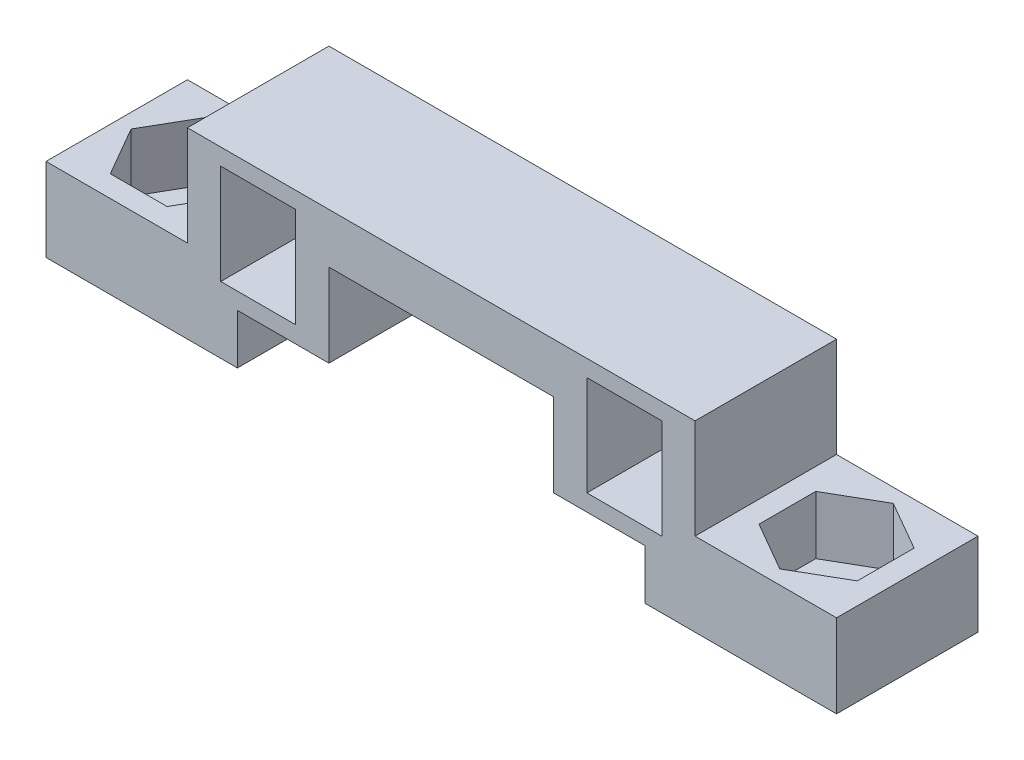
from build123d import *

# Parameters (mm, degrees)
SKETCH1_W           = 8.5
SKETCH1_H           = 8.5
BOSS_EXTRUDE1_DEPTH = 3.5
SKETCH2_W           = 8.5
SKETCH2_H           = 8.5
SKETCH2_R           = 1.5
BOSS_EXTRUDE2_DEPTH = 1.5
SKETCH3_W           = 8.5
SKETCH3_H           = 5
BOSS_EXTRUDE3_DEPTH = 3
SKETCH4_W           = 3
SKETCH4_H           = 8.5
BOSS_EXTRUDE4_DEPTH = 6
SKETCH5_W           = 8.5
SKETCH5_H           = 3
BOSS_EXTRUDE5_DEPTH = 27.5
SKETCH6_W           = 3
SKETCH6_H           = 8.5
BOSS_EXTRUDE6_DEPTH = 8
SKETCH7_W           = 8.5
SKETCH7_H           = 5
BOSS_EXTRUDE7_DEPTH = 8.5
CUT_EXTRUDE1_DEPTH  = 3.5
SKETCH10_R          = 1.5
CUT_EXTRUDE3_DEPTH  = 3.5
BOSS_EXTRUDE8_REACH = 38
SKETCH15_W          = 8.5
SKETCH15_H          = 5
SKETCH16_W          = 4.5
SKETCH16_H          = 6
CUT_EXTRUDE4_DEPTH  = 10
SKETCH17_W          = 13.5
SKETCH17_H          = 5
CUT_EXTRUDE5_DEPTH  = 10


with BuildPart() as part:
    # Sketch1 → Boss-Extrude1 (new body)
    with BuildSketch(Plane(origin=(0, 0, 0), x_dir=(1, 0, 0), z_dir=(0, 1, 0))):
        with Locations((4.25, 4.25)):
            Rectangle(SKETCH1_W, SKETCH1_H)
        Polygon((5.985496764, 7.195964334), (2.575496764, 7.195964334), (0.870496764, 4.242817707), (2.575496764, 1.28967108), (5.985496764, 1.28967108), (7.690496764, 4.242817707), align=None, mode=Mode.SUBTRACT)
    extrude(amount=BOSS_EXTRUDE1_DEPTH)

    # Sketch2 → Boss-Extrude2 (add)
    with BuildSketch(Plane.XZ):
        with Locations((4.25, -4.25)):
            Rectangle(SKETCH2_W, SKETCH2_H)
        with Locations((4.25, -4.25)):
            Circle(SKETCH2_R, mode=Mode.SUBTRACT)
    extrude(amount=BOSS_EXTRUDE2_DEPTH)

    # Sketch3 → Boss-Extrude3 (add)
    with BuildSketch(Plane(origin=(8.5, 0, 0), x_dir=(0, 0, -1), z_dir=(1, 0, 0))):
        with Locations((4.25, 1)):
            Rectangle(SKETCH3_W, SKETCH3_H)
    extrude(amount=BOSS_EXTRUDE3_DEPTH)

    # Sketch4 → Boss-Extrude4 (add)
    with BuildSketch(Plane(origin=(0, 3.5, 0), x_dir=(1, 0, 0), z_dir=(0, 1, 0))):
        with Locations((10, 4.25)):
            Rectangle(SKETCH4_W, SKETCH4_H)
    extrude(amount=BOSS_EXTRUDE4_DEPTH)

    # Sketch5 → Boss-Extrude5 (add)
    with BuildSketch(Plane(origin=(11.5, 0, 0), x_dir=(0, 0, -1), z_dir=(1, 0, 0))):
        with Locations((4.25, 8)):
            Rectangle(SKETCH5_W, SKETCH5_H)
    extrude(amount=BOSS_EXTRUDE5_DEPTH)

    # Sketch6 → Boss-Extrude6 (add)
    with BuildSketch(Plane.XZ.offset(-6.5)):
        with Locations((37.5, -4.25)):
            Rectangle(SKETCH6_W, SKETCH6_H)
    extrude(amount=BOSS_EXTRUDE6_DEPTH)

    # Sketch7 → Boss-Extrude7 (add)
    with BuildSketch(Plane(origin=(39, 0, 0), x_dir=(0, 0, -1), z_dir=(1, 0, 0))):
        with Locations((4.25, 1)):
            Rectangle(SKETCH7_W, SKETCH7_H)
    extrude(amount=BOSS_EXTRUDE7_DEPTH)

    # Sketch8 → Cut-Extrude1 (cut)
    with BuildSketch(Plane(origin=(0, 3.5, 0), x_dir=(1, 0, 0), z_dir=(0, 1, 0))):
        Polygon((46.203146627, 5.955), (43.25, 7.66), (40.296853373, 5.955), (40.296853373, 2.545), (43.25, 0.84), (46.203146627, 2.545), align=None)
    extrude(amount=-CUT_EXTRUDE1_DEPTH, mode=Mode.SUBTRACT)

    # Sketch10 → Cut-Extrude3 (cut)
    with BuildSketch(Plane(origin=(0, 0, 0), x_dir=(1, 0, 0), z_dir=(0, 1, 0))):
        with Locations((43.25, 4.25)):
            Circle(SKETCH10_R)
    extrude(amount=-CUT_EXTRUDE3_DEPTH, mode=Mode.SUBTRACT)

    # Sketch15 → Boss-Extrude8 (add, up to next)
    with BuildSketch(Plane(origin=(11.5, 0, 0), x_dir=(0, 0, -1), z_dir=(1, 0, 0)), mode=Mode.PRIVATE) as boss_extrude8_sk1:
        with Locations((4.25, 4)):
            Rectangle(SKETCH15_W, SKETCH15_H)
    boss_extrude8_tool1 = extrude(boss_extrude8_sk1.sketch, amount=BOSS_EXTRUDE8_REACH, mode=Mode.PRIVATE) - part.part
    add(boss_extrude8_tool1.solids().sort_by_distance((11.5, 4, -4.25))[0])

    # Sketch16 → Cut-Extrude4 (cut)
    with BuildSketch(Plane.XY):
        with Locations((12.75, 5.5)):
            Rectangle(SKETCH16_W, SKETCH16_H)
        with Locations((34.75, 5.5)):
            Rectangle(SKETCH16_W, SKETCH16_H)
    extrude(amount=-CUT_EXTRUDE4_DEPTH, mode=Mode.SUBTRACT)

    # Sketch17 → Cut-Extrude5 (cut)
    with BuildSketch(Plane.XY):
        with Locations((23.75, 4)):
            Rectangle(SKETCH17_W, SKETCH17_H)
    extrude(amount=-CUT_EXTRUDE5_DEPTH, mode=Mode.SUBTRACT)


solid = part.part
